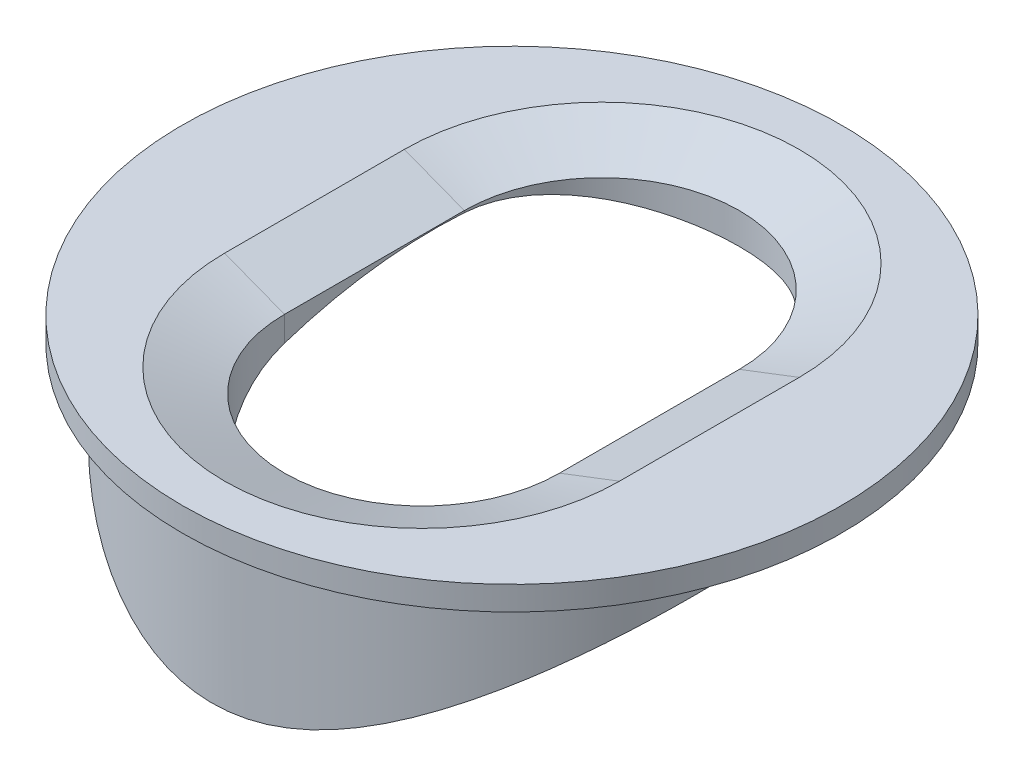
from build123d import *

# Parameters (mm, degrees)
SKETCH1_R               = 5
BOSS_EXTRUDE1_DEPTH     = 5
SKETCH2_R               = 5.5
BOSS_EXTRUDE2_DEPTH     = 0.4
CUT_EXTRUDE1_DEPTH      = 6.4
SKETCH5_R               = 8
CUT_EXTRUDE2_DEPTH      = 6.5
CUT_EXTRUDE2_DEPTH_BACK = 6.5
CHAMFER4_SIZE           = 1
CHAMFER4_SIZE2          = 0.383864035


with BuildPart() as part:
    # Sketch1 → Boss-Extrude1 (new body)
    with BuildSketch(Plane(origin=(0, 0, 0), x_dir=(1, 0, 0), z_dir=(0, 1, 0))):
        Circle(SKETCH1_R)
    extrude(amount=BOSS_EXTRUDE1_DEPTH)

    # Sketch2 → Boss-Extrude2 (add)
    with BuildSketch(Plane(origin=(0, 5, 0), x_dir=(1, 0, 0), z_dir=(0, 1, 0))):
        Circle(SKETCH2_R)
    extrude(amount=BOSS_EXTRUDE2_DEPTH)

    # Sketch4 → Cut-Extrude1 (cut, through all)
    with BuildSketch(Plane(origin=(0, 5.4, 0), x_dir=(1, 0, 0), z_dir=(0, 1, 0))):
        with BuildLine():
            Line((2.295250379, 1.5), (2.295250379, -1.5))
            ThreePointArc((2.295250379, -1.5), (0, -3.795250379), (-2.295250379, -1.5))
            Line((-2.295250379, -1.5), (-2.295250379, 1.5))
            ThreePointArc((-2.295250379, 1.5), (0, 3.795250379), (2.295250379, 1.5))
        make_face()
    extrude(amount=-CUT_EXTRUDE1_DEPTH, mode=Mode.SUBTRACT)

    # Sketch5 → Cut-Extrude2 (cut, two sides)
    with BuildSketch(Plane(origin=(0, 0, 0), x_dir=(0, 0, -1), z_dir=(1, 0, 0))) as cut_extrude2_sk:
        with Locations((1, -3)):
            Circle(SKETCH5_R)
    extrude(amount=CUT_EXTRUDE2_DEPTH, mode=Mode.SUBTRACT)
    extrude(cut_extrude2_sk.sketch, amount=-CUT_EXTRUDE2_DEPTH_BACK, mode=Mode.SUBTRACT)

    # Chamfer4
    chamfer4_edges = [part.edges().sort_by_distance(p)[0] for p in [
        (0, 5.4, -3.795250379),
        (-2.295250379, 5.4, 0),
        (0, 5.4, 3.795250379),
        (2.295250379, 5.4, 0),
    ]]
    chamfer4_side = [part.faces().sort_by_distance(p)[0] for p in [
        (-5.344436508, 5.4, 0),
    ]]
    chamfer(chamfer4_edges, length=CHAMFER4_SIZE, length2=CHAMFER4_SIZE2, reference=chamfer4_side[0])


solid = part.part
